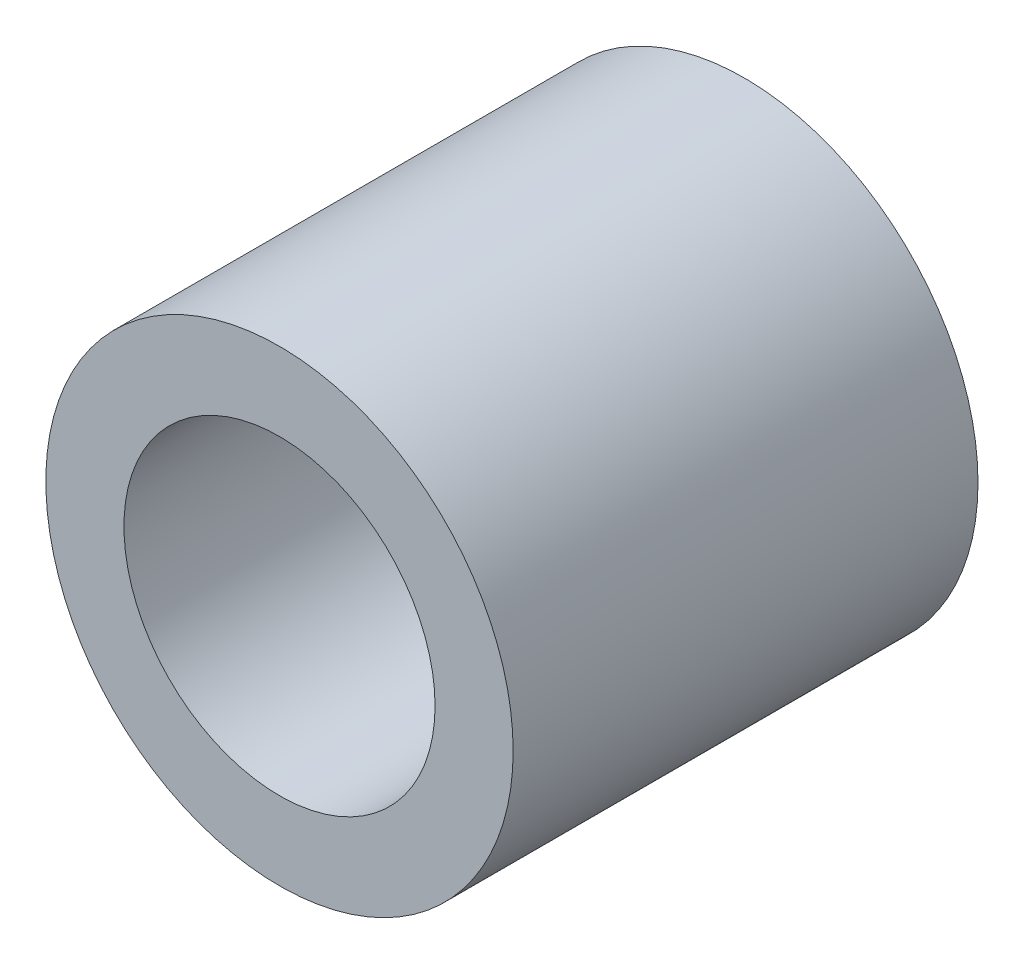
from build123d import *

# Parameters (mm, degrees)
SKETCH1_R      = 4.7879
SKETCH1_R_2    = 3.1877
EXTRUDE1_DEPTH = 4.7625


with BuildPart() as part:
    # Sketch1 → Extrude1 (new body, symmetric)
    with BuildSketch(Plane.XY):
        Circle(SKETCH1_R)
        Circle(SKETCH1_R_2, mode=Mode.SUBTRACT)
    extrude(amount=EXTRUDE1_DEPTH, both=True)


solid = part.part
